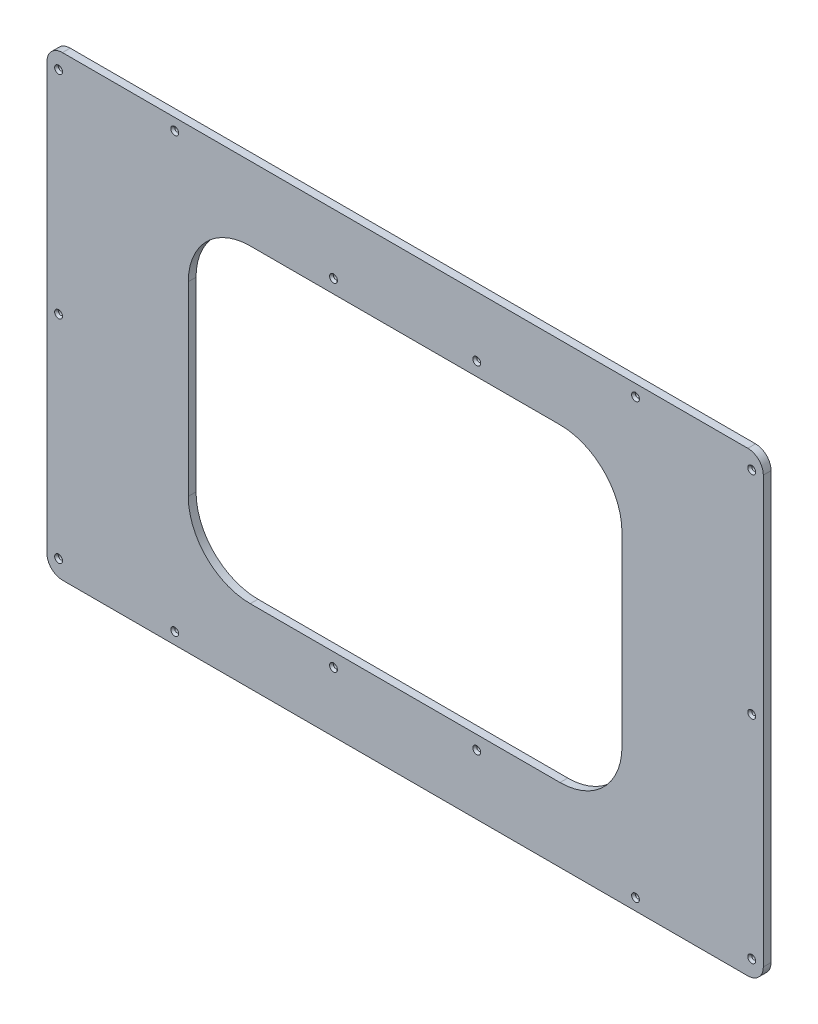
from build123d import *

# Parameters (mm, degrees)
SKETCH1_W                                        = 1174.75
SKETCH1_H                                        = 749.3
SKETCH1_W_2                                      = 711.2
SKETCH1_H_2                                      = 508
BOSS_EXTRUDE1_DEPTH                              = 12.7
FILLET1_R                                        = 101.6
CSK_FOR_1_4_FLAT_HEAD_MACHINE_SCREW1_D           = 6.7564
CSK_FOR_1_4_FLAT_HEAD_MACHINE_SCREW1_CSINK_D     = 12.8778
CSK_FOR_1_4_FLAT_HEAD_MACHINE_SCREW1_CSINK_ANGLE = 82
FILLET2_R                                        = 25.4


with BuildPart() as part:
    # Sketch1 → Boss-Extrude1 (new body)
    with BuildSketch(Plane.XY):
        Rectangle(SKETCH1_W, SKETCH1_H)
        Rectangle(SKETCH1_W_2, SKETCH1_H_2, mode=Mode.SUBTRACT)
    extrude(amount=BOSS_EXTRUDE1_DEPTH)

    # Fillet1
    fillet1_edges = [part.edges().sort_by_distance(p)[0] for p in [
        (355.6, -254, 6.35),
        (355.6, 254, 6.35),
        (-355.6, 254, 6.35),
        (-355.6, -254, 6.35),
    ]]
    fillet(fillet1_edges, radius=FILLET1_R)

    # CSK for 1/4 Flat Head Machine Screw1 (through all)
    with Locations(Plane.XY.offset(12.7)):
        with Locations((-568.325, -347.218), (-568.325, 0), (-377.825, 355.6), (-377.825, -355.6), (-568.325, 347.218), (377.825, -355.6), (568.325, -347.218), (568.325, 0), (568.325, 347.218), (377.825, 355.6), (-117.475, -276.225), (-117.475, 276.225), (117.475, 276.225), (117.475, -276.225)):
            CounterSinkHole(CSK_FOR_1_4_FLAT_HEAD_MACHINE_SCREW1_D / 2, CSK_FOR_1_4_FLAT_HEAD_MACHINE_SCREW1_CSINK_D / 2, counter_sink_angle=CSK_FOR_1_4_FLAT_HEAD_MACHINE_SCREW1_CSINK_ANGLE)

    # Fillet2
    fillet2_edges = [part.edges().sort_by_distance(p)[0] for p in [
        (587.375, -374.65, 6.35),
        (-587.375, -374.65, 6.35),
        (-587.375, 374.65, 6.35),
        (587.375, 374.65, 6.35),
    ]]
    fillet(fillet2_edges, radius=FILLET2_R)


solid = part.part
